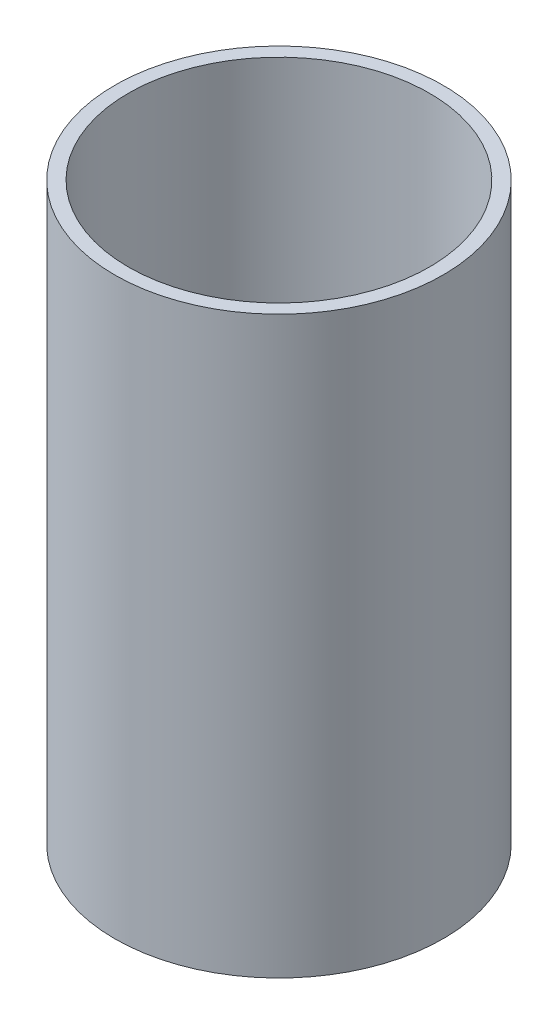
from build123d import *

# Parameters (mm, degrees)
SKETCH1_R           = 12
SKETCH1_R_2         = 11
BOSS_EXTRUDE1_DEPTH = 21


with BuildPart() as part:
    # Sketch1 → Boss-Extrude1 (new body, symmetric)
    with BuildSketch(Plane(origin=(0, 0, 0), x_dir=(1, 0, 0), z_dir=(0, 1, 0))):
        Circle(SKETCH1_R)
        Circle(SKETCH1_R_2, mode=Mode.SUBTRACT)
    extrude(amount=BOSS_EXTRUDE1_DEPTH, both=True)


solid = part.part
